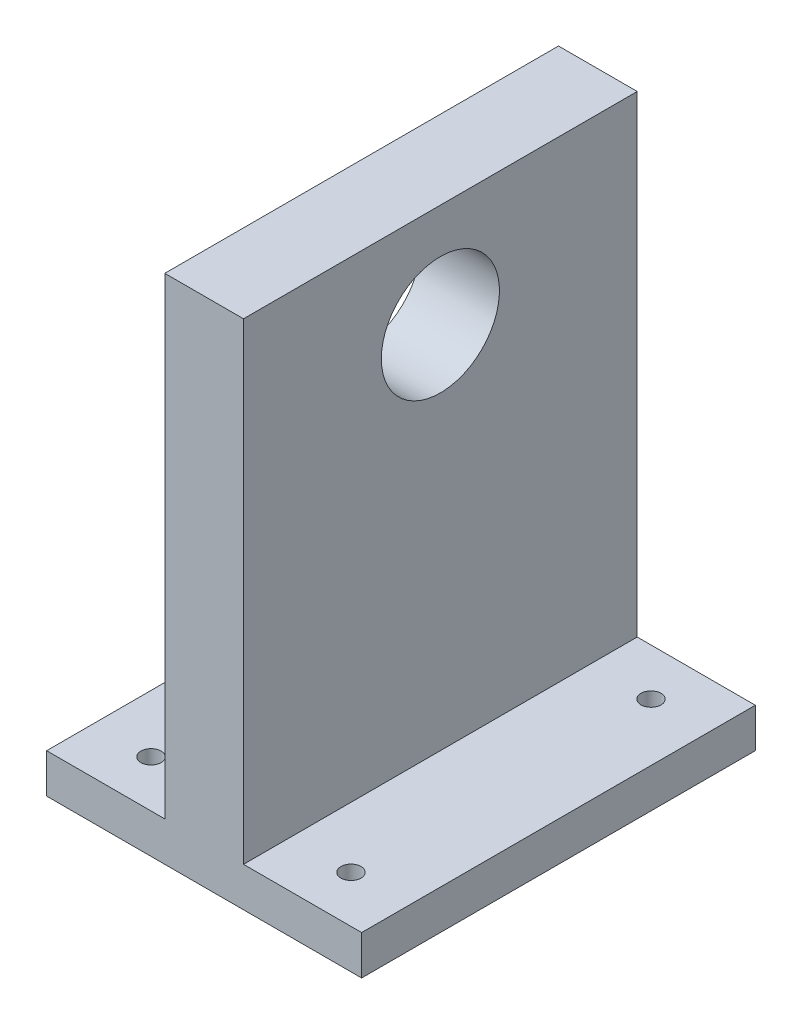
from build123d import *

# Parameters (mm, degrees)
SKETCH2_W           = 80
SKETCH2_H           = 100
BOSS_EXTRUDE1_DEPTH = 10
SKETCH3_W           = 20
SKETCH3_H           = 100
BOSS_EXTRUDE2_DEPTH = 120
SKETCH5_R           = 2.555
CUT_EXTRUDE2_DEPTH  = 55
SKETCH4_R           = 15
CUT_EXTRUDE3_DEPTH  = 29


with BuildPart() as part:
    # Sketch2 → Boss-Extrude1 (new body)
    with BuildSketch(Plane(origin=(0, 0, 0), x_dir=(1, 0, 0), z_dir=(0, 1, 0))):
        Rectangle(SKETCH2_W, SKETCH2_H)
    extrude(amount=BOSS_EXTRUDE1_DEPTH)

    # Sketch3 → Boss-Extrude2 (add)
    with BuildSketch(Plane(origin=(0, 10, 0), x_dir=(1, 0, 0), z_dir=(0, 1, 0))):
        Rectangle(SKETCH3_W, SKETCH3_H)
    extrude(amount=BOSS_EXTRUDE2_DEPTH)

    # Sketch5 → Cut-Extrude2 (cut)
    with BuildSketch(Plane.XZ):
        with Locations((-25.4, -38.1)):
            Circle(SKETCH5_R)
        with Locations((25.4, -38.1)):
            Circle(SKETCH5_R)
        with Locations((-25.4, 38.1)):
            Circle(SKETCH5_R)
        with Locations((25.4, 38.1)):
            Circle(SKETCH5_R)
    extrude(amount=-CUT_EXTRUDE2_DEPTH, mode=Mode.SUBTRACT)

    # Sketch4 → Cut-Extrude3 (cut)
    with BuildSketch(Plane.ZY.offset(10)):
        with Locations((0, 103.69)):
            Circle(SKETCH4_R)
    extrude(amount=-CUT_EXTRUDE3_DEPTH, mode=Mode.SUBTRACT)


solid = part.part
